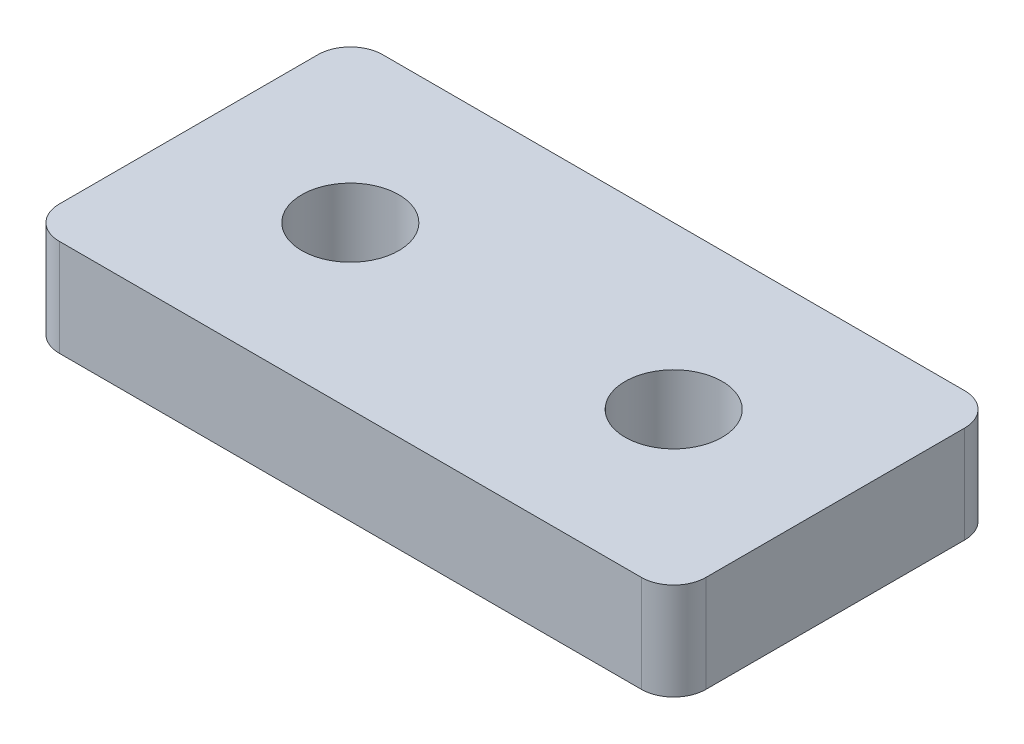
from build123d import *

# Parameters (mm, degrees)
SKETCH1_W           = 20
SKETCH1_H           = 10
SKETCH1_R           = 1.5
BOSS_EXTRUDE1_DEPTH = 3
FILLET1_R           = 1


with BuildPart() as part:
    # Sketch1 → Boss-Extrude1 (new body)
    with BuildSketch(Plane(origin=(0, 0, 0), x_dir=(1, 0, 0), z_dir=(0, 1, 0))):
        with Locations((10, 5)):
            Rectangle(SKETCH1_W, SKETCH1_H)
        with Locations((5, 5)):
            Circle(SKETCH1_R, mode=Mode.SUBTRACT)
        with Locations((15, 5)):
            Circle(SKETCH1_R, mode=Mode.SUBTRACT)
    extrude(amount=BOSS_EXTRUDE1_DEPTH)

    # Fillet1
    fillet1_edges = [part.edges().sort_by_distance(p)[0] for p in [
        (0, 1.5, -10),
        (20, 1.5, -10),
        (20, 1.5, 0),
        (0, 1.5, 0),
    ]]
    fillet(fillet1_edges, radius=FILLET1_R)


solid = part.part
